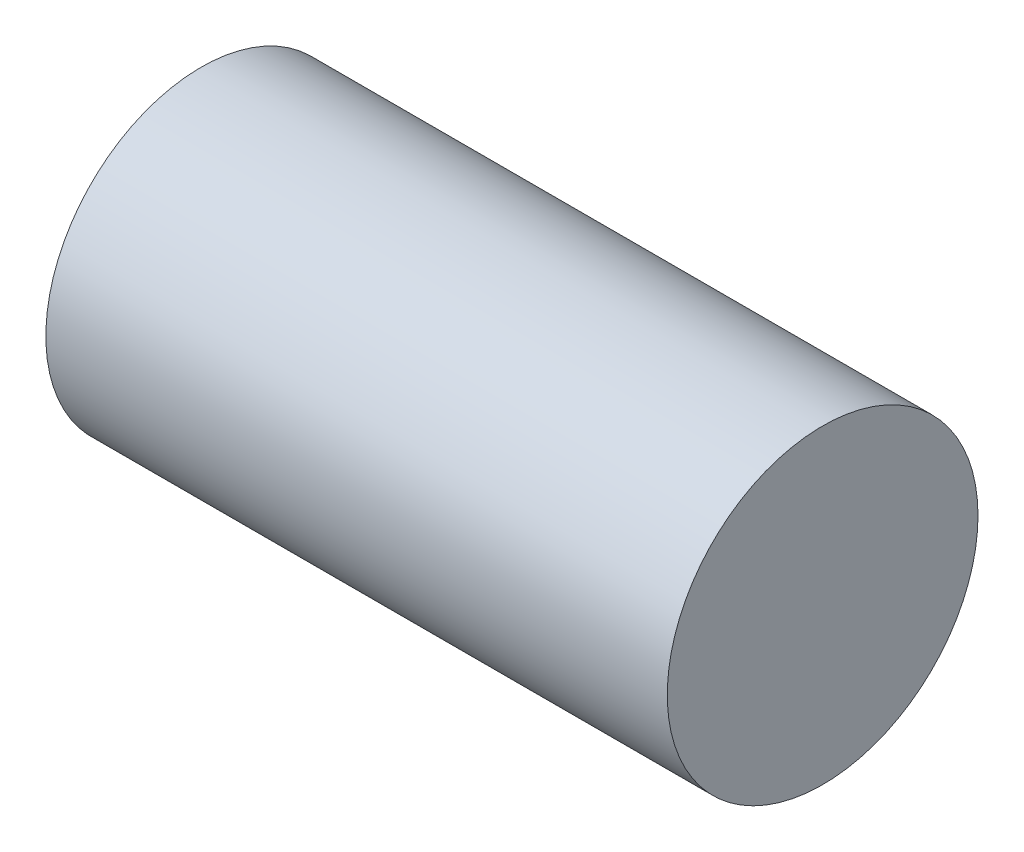
from build123d import *

# Parameters (mm, degrees)
SKETCH1_R           = 15
BOSS_EXTRUDE1_DEPTH = 60


with BuildPart() as part:
    # Sketch1 → Boss-Extrude1 (new body)
    with BuildSketch(Plane(origin=(0, 0, 0), x_dir=(0, 0, -1), z_dir=(1, 0, 0))):
        Circle(SKETCH1_R)
    extrude(amount=BOSS_EXTRUDE1_DEPTH)


solid = part.part
